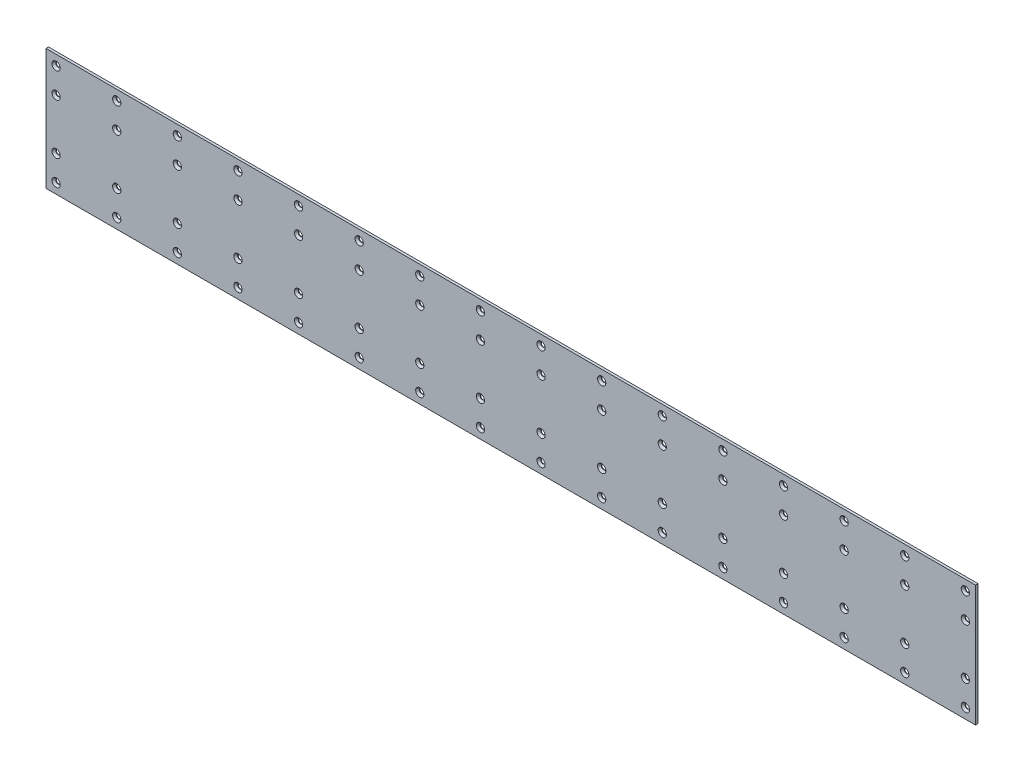
from build123d import *

# Parameters (mm, degrees)
SKETCH1_W                                 = 1168.4
SKETCH1_H                                 = 152.4
BOSS_EXTRUDE1_DEPTH                       = 3.175
CSK_FOR_0_FLAT_HEAD_MACHINE_SCREW_2_COUNT = 2
CSK_FOR_0_FLAT_HEAD_MACHINE_SCREW_2_PITCH = 31.75
CSK_FOR_0_FLAT_HEAD_MACHINE_SCREW_3_COUNT = 2
CSK_FOR_0_FLAT_HEAD_MACHINE_SCREW_3_PITCH = 95.25
CSK_FOR_0_FLAT_HEAD_MACHINE_SCREW_4_COUNT = 2
CSK_FOR_0_FLAT_HEAD_MACHINE_SCREW_4_PITCH = 127
LPATTERN1_COUNT                           = 16
LPATTERN1_PITCH                           = 76.2


with BuildPart() as part:
    # Sketch1 → Boss-Extrude1 (new body)
    with BuildSketch(Plane.XY):
        with Locations((584.2, 76.2)):
            Rectangle(SKETCH1_W, SKETCH1_H)
    extrude(amount=-BOSS_EXTRUDE1_DEPTH)

    # Sketch3 → CSK for #0 Flat Head Machine Screw (100)1 (revolve, cut)
    with BuildSketch(Plane(origin=(12.7, 139.7, 0), x_dir=(0, -1, 0), z_dir=(1, 0, 0))):
        Polygon((0, 0), (0, 3.175), (2.7559, 3.175), (2.7559, 2.4384), (5.1943, 0), align=None)
    csk_for_0_flat_head_machine_screw_100 = revolve(axis=Axis((12.7, 139.7, 6.35), (0, 0, -1)), mode=Mode.SUBTRACT)

    # CSK for _0 Flat Head Machine Screw _ 2: CSK for #0 Flat Head Machine Screw (100)1 ×2
    with Locations(*[(0, -i * CSK_FOR_0_FLAT_HEAD_MACHINE_SCREW_2_PITCH, 0) for i in range(1, CSK_FOR_0_FLAT_HEAD_MACHINE_SCREW_2_COUNT)]):
        add(csk_for_0_flat_head_machine_screw_100, mode=Mode.SUBTRACT)

    # CSK for _0 Flat Head Machine Screw _ 3: CSK for #0 Flat Head Machine Screw (100)1 ×2
    with Locations(*[(0, -i * CSK_FOR_0_FLAT_HEAD_MACHINE_SCREW_3_PITCH, 0) for i in range(1, CSK_FOR_0_FLAT_HEAD_MACHINE_SCREW_3_COUNT)]):
        add(csk_for_0_flat_head_machine_screw_100, mode=Mode.SUBTRACT)

    # CSK for _0 Flat Head Machine Screw _ 4: CSK for #0 Flat Head Machine Screw (100)1 ×2
    with Locations(*[(0, -i * CSK_FOR_0_FLAT_HEAD_MACHINE_SCREW_4_PITCH, 0) for i in range(1, CSK_FOR_0_FLAT_HEAD_MACHINE_SCREW_4_COUNT)]):
        add(csk_for_0_flat_head_machine_screw_100, mode=Mode.SUBTRACT)

    # LPattern1: CSK for #0 Flat Head Machine Screw (100)1 ×16
    with Locations(*[(i * LPATTERN1_PITCH, 0, 0) for i in range(1, LPATTERN1_COUNT)]):
        add(csk_for_0_flat_head_machine_screw_100, mode=Mode.SUBTRACT)

    # LPattern1 copy 1 sketch → LPattern1 copy 1 (revolve, cut)
    with BuildSketch(Plane(origin=(88.9, 107.95, 0), x_dir=(0, -1, 0), z_dir=(1, 0, 0))):
        Polygon((0, 0), (0, 3.175), (2.7559, 3.175), (2.7559, 2.4384), (5.1943, 0), align=None)
    revolve(axis=Axis((88.9, 107.95, 6.35), (0, 0, -1)), mode=Mode.SUBTRACT)

    # LPattern1 copy 2 sketch → LPattern1 copy 2 (revolve, cut)
    with BuildSketch(Plane(origin=(165.1, 107.95, 0), x_dir=(0, -1, 0), z_dir=(1, 0, 0))):
        Polygon((0, 0), (0, 3.175), (2.7559, 3.175), (2.7559, 2.4384), (5.1943, 0), align=None)
    revolve(axis=Axis((165.1, 107.95, 6.35), (0, 0, -1)), mode=Mode.SUBTRACT)

    # LPattern1 copy 3 sketch → LPattern1 copy 3 (revolve, cut)
    with BuildSketch(Plane(origin=(241.3, 107.95, 0), x_dir=(0, -1, 0), z_dir=(1, 0, 0))):
        Polygon((0, 0), (0, 3.175), (2.7559, 3.175), (2.7559, 2.4384), (5.1943, 0), align=None)
    revolve(axis=Axis((241.3, 107.95, 6.35), (0, 0, -1)), mode=Mode.SUBTRACT)

    # LPattern1 copy 4 sketch → LPattern1 copy 4 (revolve, cut)
    with BuildSketch(Plane(origin=(317.5, 107.95, 0), x_dir=(0, -1, 0), z_dir=(1, 0, 0))):
        Polygon((0, 0), (0, 3.175), (2.7559, 3.175), (2.7559, 2.4384), (5.1943, 0), align=None)
    revolve(axis=Axis((317.5, 107.95, 6.35), (0, 0, -1)), mode=Mode.SUBTRACT)

    # LPattern1 copy 5 sketch → LPattern1 copy 5 (revolve, cut)
    with BuildSketch(Plane(origin=(393.7, 107.95, 0), x_dir=(0, -1, 0), z_dir=(1, 0, 0))):
        Polygon((0, 0), (0, 3.175), (2.7559, 3.175), (2.7559, 2.4384), (5.1943, 0), align=None)
    revolve(axis=Axis((393.7, 107.95, 6.35), (0, 0, -1)), mode=Mode.SUBTRACT)

    # LPattern1 copy 6 sketch → LPattern1 copy 6 (revolve, cut)
    with BuildSketch(Plane(origin=(469.9, 107.95, 0), x_dir=(0, -1, 0), z_dir=(1, 0, 0))):
        Polygon((0, 0), (0, 3.175), (2.7559, 3.175), (2.7559, 2.4384), (5.1943, 0), align=None)
    revolve(axis=Axis((469.9, 107.95, 6.35), (0, 0, -1)), mode=Mode.SUBTRACT)

    # LPattern1 copy 7 sketch → LPattern1 copy 7 (revolve, cut)
    with BuildSketch(Plane(origin=(546.1, 107.95, 0), x_dir=(0, -1, 0), z_dir=(1, 0, 0))):
        Polygon((0, 0), (0, 3.175), (2.7559, 3.175), (2.7559, 2.4384), (5.1943, 0), align=None)
    revolve(axis=Axis((546.1, 107.95, 6.35), (0, 0, -1)), mode=Mode.SUBTRACT)

    # LPattern1 copy 8 sketch → LPattern1 copy 8 (revolve, cut)
    with BuildSketch(Plane(origin=(622.3, 107.95, 0), x_dir=(0, -1, 0), z_dir=(1, 0, 0))):
        Polygon((0, 0), (0, 3.175), (2.7559, 3.175), (2.7559, 2.4384), (5.1943, 0), align=None)
    revolve(axis=Axis((622.3, 107.95, 6.35), (0, 0, -1)), mode=Mode.SUBTRACT)

    # LPattern1 copy 9 sketch → LPattern1 copy 9 (revolve, cut)
    with BuildSketch(Plane(origin=(698.5, 107.95, 0), x_dir=(0, -1, 0), z_dir=(1, 0, 0))):
        Polygon((0, 0), (0, 3.175), (2.7559, 3.175), (2.7559, 2.4384), (5.1943, 0), align=None)
    revolve(axis=Axis((698.5, 107.95, 6.35), (0, 0, -1)), mode=Mode.SUBTRACT)

    # LPattern1 copy 10 sketch → LPattern1 copy 10 (revolve, cut)
    with BuildSketch(Plane(origin=(774.7, 107.95, 0), x_dir=(0, -1, 0), z_dir=(1, 0, 0))):
        Polygon((0, 0), (0, 3.175), (2.7559, 3.175), (2.7559, 2.4384), (5.1943, 0), align=None)
    revolve(axis=Axis((774.7, 107.95, 6.35), (0, 0, -1)), mode=Mode.SUBTRACT)

    # LPattern1 copy 11 sketch → LPattern1 copy 11 (revolve, cut)
    with BuildSketch(Plane(origin=(850.9, 107.95, 0), x_dir=(0, -1, 0), z_dir=(1, 0, 0))):
        Polygon((0, 0), (0, 3.175), (2.7559, 3.175), (2.7559, 2.4384), (5.1943, 0), align=None)
    revolve(axis=Axis((850.9, 107.95, 6.35), (0, 0, -1)), mode=Mode.SUBTRACT)

    # LPattern1 copy 12 sketch → LPattern1 copy 12 (revolve, cut)
    with BuildSketch(Plane(origin=(927.1, 107.95, 0), x_dir=(0, -1, 0), z_dir=(1, 0, 0))):
        Polygon((0, 0), (0, 3.175), (2.7559, 3.175), (2.7559, 2.4384), (5.1943, 0), align=None)
    revolve(axis=Axis((927.1, 107.95, 6.35), (0, 0, -1)), mode=Mode.SUBTRACT)

    # LPattern1 copy 13 sketch → LPattern1 copy 13 (revolve, cut)
    with BuildSketch(Plane(origin=(1003.3, 107.95, 0), x_dir=(0, -1, 0), z_dir=(1, 0, 0))):
        Polygon((0, 0), (0, 3.175), (2.7559, 3.175), (2.7559, 2.4384), (5.1943, 0), align=None)
    revolve(axis=Axis((1003.3, 107.95, 6.35), (0, 0, -1)), mode=Mode.SUBTRACT)

    # LPattern1 copy 14 sketch → LPattern1 copy 14 (revolve, cut)
    with BuildSketch(Plane(origin=(1079.5, 107.95, 0), x_dir=(0, -1, 0), z_dir=(1, 0, 0))):
        Polygon((0, 0), (0, 3.175), (2.7559, 3.175), (2.7559, 2.4384), (5.1943, 0), align=None)
    revolve(axis=Axis((1079.5, 107.95, 6.35), (0, 0, -1)), mode=Mode.SUBTRACT)

    # LPattern1 copy 15 sketch → LPattern1 copy 15 (revolve, cut)
    with BuildSketch(Plane(origin=(1155.7, 107.95, 0), x_dir=(0, -1, 0), z_dir=(1, 0, 0))):
        Polygon((0, 0), (0, 3.175), (2.7559, 3.175), (2.7559, 2.4384), (5.1943, 0), align=None)
    revolve(axis=Axis((1155.7, 107.95, 6.35), (0, 0, -1)), mode=Mode.SUBTRACT)

    # LPattern1 copy 16 sketch → LPattern1 copy 16 (revolve, cut)
    with BuildSketch(Plane(origin=(88.9, 44.45, 0), x_dir=(0, -1, 0), z_dir=(1, 0, 0))):
        Polygon((0, 0), (0, 3.175), (2.7559, 3.175), (2.7559, 2.4384), (5.1943, 0), align=None)
    revolve(axis=Axis((88.9, 44.45, 6.35), (0, 0, -1)), mode=Mode.SUBTRACT)

    # LPattern1 copy 17 sketch → LPattern1 copy 17 (revolve, cut)
    with BuildSketch(Plane(origin=(165.1, 44.45, 0), x_dir=(0, -1, 0), z_dir=(1, 0, 0))):
        Polygon((0, 0), (0, 3.175), (2.7559, 3.175), (2.7559, 2.4384), (5.1943, 0), align=None)
    revolve(axis=Axis((165.1, 44.45, 6.35), (0, 0, -1)), mode=Mode.SUBTRACT)

    # LPattern1 copy 18 sketch → LPattern1 copy 18 (revolve, cut)
    with BuildSketch(Plane(origin=(241.3, 44.45, 0), x_dir=(0, -1, 0), z_dir=(1, 0, 0))):
        Polygon((0, 0), (0, 3.175), (2.7559, 3.175), (2.7559, 2.4384), (5.1943, 0), align=None)
    revolve(axis=Axis((241.3, 44.45, 6.35), (0, 0, -1)), mode=Mode.SUBTRACT)

    # LPattern1 copy 19 sketch → LPattern1 copy 19 (revolve, cut)
    with BuildSketch(Plane(origin=(317.5, 44.45, 0), x_dir=(0, -1, 0), z_dir=(1, 0, 0))):
        Polygon((0, 0), (0, 3.175), (2.7559, 3.175), (2.7559, 2.4384), (5.1943, 0), align=None)
    revolve(axis=Axis((317.5, 44.45, 6.35), (0, 0, -1)), mode=Mode.SUBTRACT)

    # LPattern1 copy 20 sketch → LPattern1 copy 20 (revolve, cut)
    with BuildSketch(Plane(origin=(393.7, 44.45, 0), x_dir=(0, -1, 0), z_dir=(1, 0, 0))):
        Polygon((0, 0), (0, 3.175), (2.7559, 3.175), (2.7559, 2.4384), (5.1943, 0), align=None)
    revolve(axis=Axis((393.7, 44.45, 6.35), (0, 0, -1)), mode=Mode.SUBTRACT)

    # LPattern1 copy 21 sketch → LPattern1 copy 21 (revolve, cut)
    with BuildSketch(Plane(origin=(469.9, 44.45, 0), x_dir=(0, -1, 0), z_dir=(1, 0, 0))):
        Polygon((0, 0), (0, 3.175), (2.7559, 3.175), (2.7559, 2.4384), (5.1943, 0), align=None)
    revolve(axis=Axis((469.9, 44.45, 6.35), (0, 0, -1)), mode=Mode.SUBTRACT)

    # LPattern1 copy 22 sketch → LPattern1 copy 22 (revolve, cut)
    with BuildSketch(Plane(origin=(546.1, 44.45, 0), x_dir=(0, -1, 0), z_dir=(1, 0, 0))):
        Polygon((0, 0), (0, 3.175), (2.7559, 3.175), (2.7559, 2.4384), (5.1943, 0), align=None)
    revolve(axis=Axis((546.1, 44.45, 6.35), (0, 0, -1)), mode=Mode.SUBTRACT)

    # LPattern1 copy 23 sketch → LPattern1 copy 23 (revolve, cut)
    with BuildSketch(Plane(origin=(622.3, 44.45, 0), x_dir=(0, -1, 0), z_dir=(1, 0, 0))):
        Polygon((0, 0), (0, 3.175), (2.7559, 3.175), (2.7559, 2.4384), (5.1943, 0), align=None)
    revolve(axis=Axis((622.3, 44.45, 6.35), (0, 0, -1)), mode=Mode.SUBTRACT)

    # LPattern1 copy 24 sketch → LPattern1 copy 24 (revolve, cut)
    with BuildSketch(Plane(origin=(698.5, 44.45, 0), x_dir=(0, -1, 0), z_dir=(1, 0, 0))):
        Polygon((0, 0), (0, 3.175), (2.7559, 3.175), (2.7559, 2.4384), (5.1943, 0), align=None)
    revolve(axis=Axis((698.5, 44.45, 6.35), (0, 0, -1)), mode=Mode.SUBTRACT)

    # LPattern1 copy 25 sketch → LPattern1 copy 25 (revolve, cut)
    with BuildSketch(Plane(origin=(774.7, 44.45, 0), x_dir=(0, -1, 0), z_dir=(1, 0, 0))):
        Polygon((0, 0), (0, 3.175), (2.7559, 3.175), (2.7559, 2.4384), (5.1943, 0), align=None)
    revolve(axis=Axis((774.7, 44.45, 6.35), (0, 0, -1)), mode=Mode.SUBTRACT)

    # LPattern1 copy 26 sketch → LPattern1 copy 26 (revolve, cut)
    with BuildSketch(Plane(origin=(850.9, 44.45, 0), x_dir=(0, -1, 0), z_dir=(1, 0, 0))):
        Polygon((0, 0), (0, 3.175), (2.7559, 3.175), (2.7559, 2.4384), (5.1943, 0), align=None)
    revolve(axis=Axis((850.9, 44.45, 6.35), (0, 0, -1)), mode=Mode.SUBTRACT)

    # LPattern1 copy 27 sketch → LPattern1 copy 27 (revolve, cut)
    with BuildSketch(Plane(origin=(927.1, 44.45, 0), x_dir=(0, -1, 0), z_dir=(1, 0, 0))):
        Polygon((0, 0), (0, 3.175), (2.7559, 3.175), (2.7559, 2.4384), (5.1943, 0), align=None)
    revolve(axis=Axis((927.1, 44.45, 6.35), (0, 0, -1)), mode=Mode.SUBTRACT)

    # LPattern1 copy 28 sketch → LPattern1 copy 28 (revolve, cut)
    with BuildSketch(Plane(origin=(1003.3, 44.45, 0), x_dir=(0, -1, 0), z_dir=(1, 0, 0))):
        Polygon((0, 0), (0, 3.175), (2.7559, 3.175), (2.7559, 2.4384), (5.1943, 0), align=None)
    revolve(axis=Axis((1003.3, 44.45, 6.35), (0, 0, -1)), mode=Mode.SUBTRACT)

    # LPattern1 copy 29 sketch → LPattern1 copy 29 (revolve, cut)
    with BuildSketch(Plane(origin=(1079.5, 44.45, 0), x_dir=(0, -1, 0), z_dir=(1, 0, 0))):
        Polygon((0, 0), (0, 3.175), (2.7559, 3.175), (2.7559, 2.4384), (5.1943, 0), align=None)
    revolve(axis=Axis((1079.5, 44.45, 6.35), (0, 0, -1)), mode=Mode.SUBTRACT)

    # LPattern1 copy 30 sketch → LPattern1 copy 30 (revolve, cut)
    with BuildSketch(Plane(origin=(1155.7, 44.45, 0), x_dir=(0, -1, 0), z_dir=(1, 0, 0))):
        Polygon((0, 0), (0, 3.175), (2.7559, 3.175), (2.7559, 2.4384), (5.1943, 0), align=None)
    revolve(axis=Axis((1155.7, 44.45, 6.35), (0, 0, -1)), mode=Mode.SUBTRACT)

    # LPattern1 copy 31 sketch → LPattern1 copy 31 (revolve, cut)
    with BuildSketch(Plane(origin=(88.9, 12.7, 0), x_dir=(0, -1, 0), z_dir=(1, 0, 0))):
        Polygon((0, 0), (0, 3.175), (2.7559, 3.175), (2.7559, 2.4384), (5.1943, 0), align=None)
    revolve(axis=Axis((88.9, 12.7, 6.35), (0, 0, -1)), mode=Mode.SUBTRACT)

    # LPattern1 copy 32 sketch → LPattern1 copy 32 (revolve, cut)
    with BuildSketch(Plane(origin=(165.1, 12.7, 0), x_dir=(0, -1, 0), z_dir=(1, 0, 0))):
        Polygon((0, 0), (0, 3.175), (2.7559, 3.175), (2.7559, 2.4384), (5.1943, 0), align=None)
    revolve(axis=Axis((165.1, 12.7, 6.35), (0, 0, -1)), mode=Mode.SUBTRACT)

    # LPattern1 copy 33 sketch → LPattern1 copy 33 (revolve, cut)
    with BuildSketch(Plane(origin=(241.3, 12.7, 0), x_dir=(0, -1, 0), z_dir=(1, 0, 0))):
        Polygon((0, 0), (0, 3.175), (2.7559, 3.175), (2.7559, 2.4384), (5.1943, 0), align=None)
    revolve(axis=Axis((241.3, 12.7, 6.35), (0, 0, -1)), mode=Mode.SUBTRACT)

    # LPattern1 copy 34 sketch → LPattern1 copy 34 (revolve, cut)
    with BuildSketch(Plane(origin=(317.5, 12.7, 0), x_dir=(0, -1, 0), z_dir=(1, 0, 0))):
        Polygon((0, 0), (0, 3.175), (2.7559, 3.175), (2.7559, 2.4384), (5.1943, 0), align=None)
    revolve(axis=Axis((317.5, 12.7, 6.35), (0, 0, -1)), mode=Mode.SUBTRACT)

    # LPattern1 copy 35 sketch → LPattern1 copy 35 (revolve, cut)
    with BuildSketch(Plane(origin=(393.7, 12.7, 0), x_dir=(0, -1, 0), z_dir=(1, 0, 0))):
        Polygon((0, 0), (0, 3.175), (2.7559, 3.175), (2.7559, 2.4384), (5.1943, 0), align=None)
    revolve(axis=Axis((393.7, 12.7, 6.35), (0, 0, -1)), mode=Mode.SUBTRACT)

    # LPattern1 copy 36 sketch → LPattern1 copy 36 (revolve, cut)
    with BuildSketch(Plane(origin=(469.9, 12.7, 0), x_dir=(0, -1, 0), z_dir=(1, 0, 0))):
        Polygon((0, 0), (0, 3.175), (2.7559, 3.175), (2.7559, 2.4384), (5.1943, 0), align=None)
    revolve(axis=Axis((469.9, 12.7, 6.35), (0, 0, -1)), mode=Mode.SUBTRACT)

    # LPattern1 copy 37 sketch → LPattern1 copy 37 (revolve, cut)
    with BuildSketch(Plane(origin=(546.1, 12.7, 0), x_dir=(0, -1, 0), z_dir=(1, 0, 0))):
        Polygon((0, 0), (0, 3.175), (2.7559, 3.175), (2.7559, 2.4384), (5.1943, 0), align=None)
    revolve(axis=Axis((546.1, 12.7, 6.35), (0, 0, -1)), mode=Mode.SUBTRACT)

    # LPattern1 copy 38 sketch → LPattern1 copy 38 (revolve, cut)
    with BuildSketch(Plane(origin=(622.3, 12.7, 0), x_dir=(0, -1, 0), z_dir=(1, 0, 0))):
        Polygon((0, 0), (0, 3.175), (2.7559, 3.175), (2.7559, 2.4384), (5.1943, 0), align=None)
    revolve(axis=Axis((622.3, 12.7, 6.35), (0, 0, -1)), mode=Mode.SUBTRACT)

    # LPattern1 copy 39 sketch → LPattern1 copy 39 (revolve, cut)
    with BuildSketch(Plane(origin=(698.5, 12.7, 0), x_dir=(0, -1, 0), z_dir=(1, 0, 0))):
        Polygon((0, 0), (0, 3.175), (2.7559, 3.175), (2.7559, 2.4384), (5.1943, 0), align=None)
    revolve(axis=Axis((698.5, 12.7, 6.35), (0, 0, -1)), mode=Mode.SUBTRACT)

    # LPattern1 copy 40 sketch → LPattern1 copy 40 (revolve, cut)
    with BuildSketch(Plane(origin=(774.7, 12.7, 0), x_dir=(0, -1, 0), z_dir=(1, 0, 0))):
        Polygon((0, 0), (0, 3.175), (2.7559, 3.175), (2.7559, 2.4384), (5.1943, 0), align=None)
    revolve(axis=Axis((774.7, 12.7, 6.35), (0, 0, -1)), mode=Mode.SUBTRACT)

    # LPattern1 copy 41 sketch → LPattern1 copy 41 (revolve, cut)
    with BuildSketch(Plane(origin=(850.9, 12.7, 0), x_dir=(0, -1, 0), z_dir=(1, 0, 0))):
        Polygon((0, 0), (0, 3.175), (2.7559, 3.175), (2.7559, 2.4384), (5.1943, 0), align=None)
    revolve(axis=Axis((850.9, 12.7, 6.35), (0, 0, -1)), mode=Mode.SUBTRACT)

    # LPattern1 copy 42 sketch → LPattern1 copy 42 (revolve, cut)
    with BuildSketch(Plane(origin=(927.1, 12.7, 0), x_dir=(0, -1, 0), z_dir=(1, 0, 0))):
        Polygon((0, 0), (0, 3.175), (2.7559, 3.175), (2.7559, 2.4384), (5.1943, 0), align=None)
    revolve(axis=Axis((927.1, 12.7, 6.35), (0, 0, -1)), mode=Mode.SUBTRACT)

    # LPattern1 copy 43 sketch → LPattern1 copy 43 (revolve, cut)
    with BuildSketch(Plane(origin=(1003.3, 12.7, 0), x_dir=(0, -1, 0), z_dir=(1, 0, 0))):
        Polygon((0, 0), (0, 3.175), (2.7559, 3.175), (2.7559, 2.4384), (5.1943, 0), align=None)
    revolve(axis=Axis((1003.3, 12.7, 6.35), (0, 0, -1)), mode=Mode.SUBTRACT)

    # LPattern1 copy 44 sketch → LPattern1 copy 44 (revolve, cut)
    with BuildSketch(Plane(origin=(1079.5, 12.7, 0), x_dir=(0, -1, 0), z_dir=(1, 0, 0))):
        Polygon((0, 0), (0, 3.175), (2.7559, 3.175), (2.7559, 2.4384), (5.1943, 0), align=None)
    revolve(axis=Axis((1079.5, 12.7, 6.35), (0, 0, -1)), mode=Mode.SUBTRACT)

    # LPattern1 copy 45 sketch → LPattern1 copy 45 (revolve, cut)
    with BuildSketch(Plane(origin=(1155.7, 12.7, 0), x_dir=(0, -1, 0), z_dir=(1, 0, 0))):
        Polygon((0, 0), (0, 3.175), (2.7559, 3.175), (2.7559, 2.4384), (5.1943, 0), align=None)
    revolve(axis=Axis((1155.7, 12.7, 6.35), (0, 0, -1)), mode=Mode.SUBTRACT)


solid = part.part
